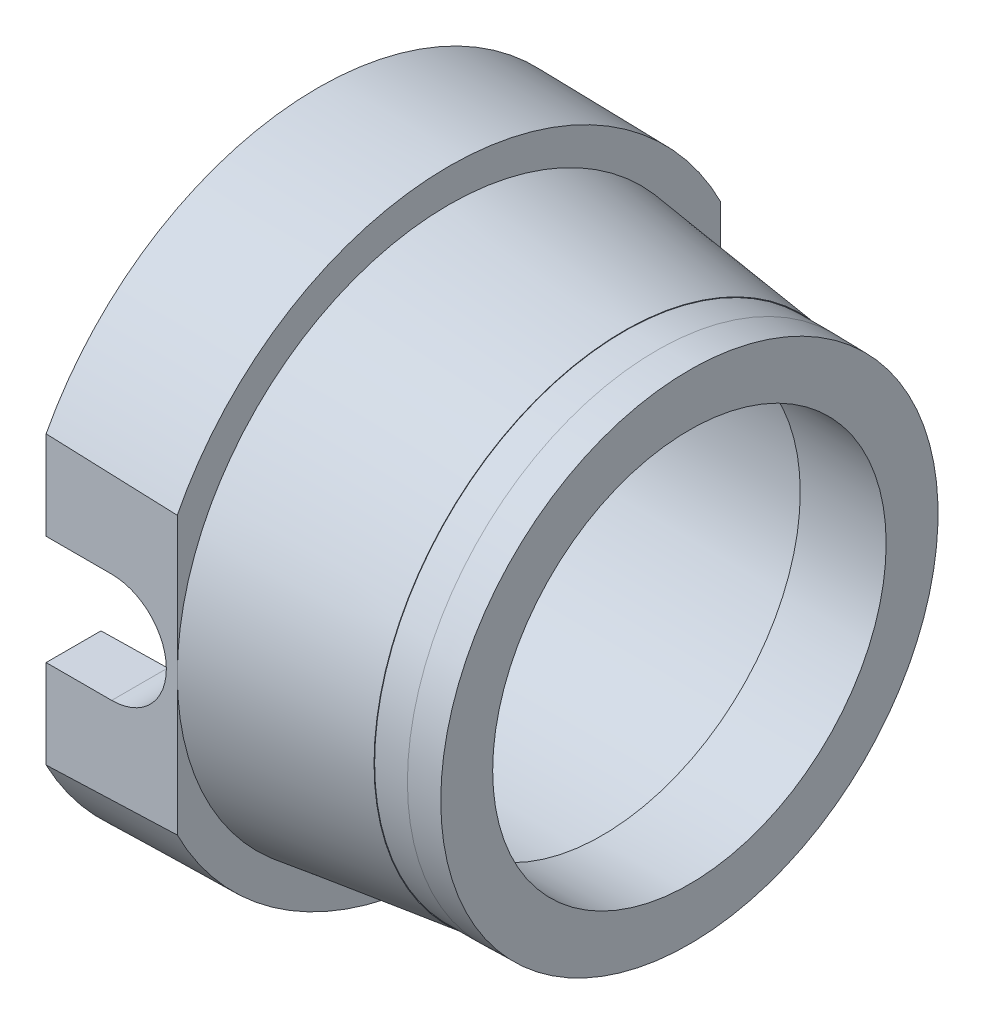
from build123d import *

# Parameters (mm, degrees)
SKETCH_2_W          = 4.013970818
SKETCH_2_H          = 10.71622578
SKETCH_2_W_2        = 3.089760279
SKETCH_2_H_2        = 12.863028926
CUT_EXTRUDE_1_DEPTH = 4
CUT_EXTRUDE_2_REACH = 14.427
SKETCH_3_R          = 1.25
SKETCH_3_W          = 1.5
SKETCH_3_H          = 2.5


with BuildPart() as part:
    # 草图1 → 旋转1 (revolve)
    with BuildSketch(Plane.XY, mode=Mode.PRIVATE) as revolve_1_sk:
        Polygon((7, -5.713091299), (7, -5.7), (7.75, -5.7), (8.5, -5.686908701), (8.5, -4.5), (6.5, -4.53491013), (6.5, -5), (0, -5.113457922), (0, -7.026182597), (3, -6.973817403), (3, -6.213444663), align=None)
    revolve(revolve_1_sk.sketch.rotate(Axis((-162.804450563, 0, 0), (1, 0, 0)), 270), axis=Axis((-162.804450563, 0, 0), (1, 0, 0)))  # turned: the seam where the file's is

    # 草图2 → 切除-拉伸1 (cut, through all)
    with BuildSketch(Plane(origin=(3, 0, 0), x_dir=(0, 0, -1), z_dir=(1, 0, 0))):
        with Locations((8.220430072, 0.592212477)):
            Rectangle(SKETCH_2_W, SKETCH_2_H)
        with Locations((-7.758324803, -0.481189096)):
            Rectangle(SKETCH_2_W_2, SKETCH_2_H_2)
    extrude(amount=-CUT_EXTRUDE_1_DEPTH, mode=Mode.SUBTRACT)

    # 切除-拉伸2: up to this cone (the profile starts outside it)
    cut_extrude_2_end = Plane(origin=(1.125, 0, 0), z_dir=(-1, 0, 0)) * Cone(4.737810595, 5.449831353, 40.791641948, mode=Mode.PRIVATE)
    # 草图3 → 切除-拉伸2 (cut, up to the surface)
    with BuildSketch(Plane.XY.offset(6.213444663), mode=Mode.PRIVATE) as cut_extrude_2_sk1:
        with Locations((1.5, 0)):
            Circle(SKETCH_3_R)
    cut_extrude_2_tool1 = extrude(cut_extrude_2_sk1.sketch, amount=-CUT_EXTRUDE_2_REACH, mode=Mode.PRIVATE) - cut_extrude_2_end
    add(cut_extrude_2_tool1.solids().sort_by_distance((1.5, 0, 6.213445))[0], mode=Mode.SUBTRACT)
    # 草图3 → 切除-拉伸2 (cut, up to the surface)
    with BuildSketch(Plane.XY.offset(6.213444663), mode=Mode.PRIVATE) as cut_extrude_2_sk2:
        with Locations((0.75, 0)):
            Rectangle(SKETCH_3_W, SKETCH_3_H)
    cut_extrude_2_tool2 = extrude(cut_extrude_2_sk2.sketch, amount=-CUT_EXTRUDE_2_REACH, mode=Mode.PRIVATE) - cut_extrude_2_end
    add(cut_extrude_2_tool2.solids().sort_by_distance((0.75, 0, 6.213445))[0], mode=Mode.SUBTRACT)


solid = part.part
